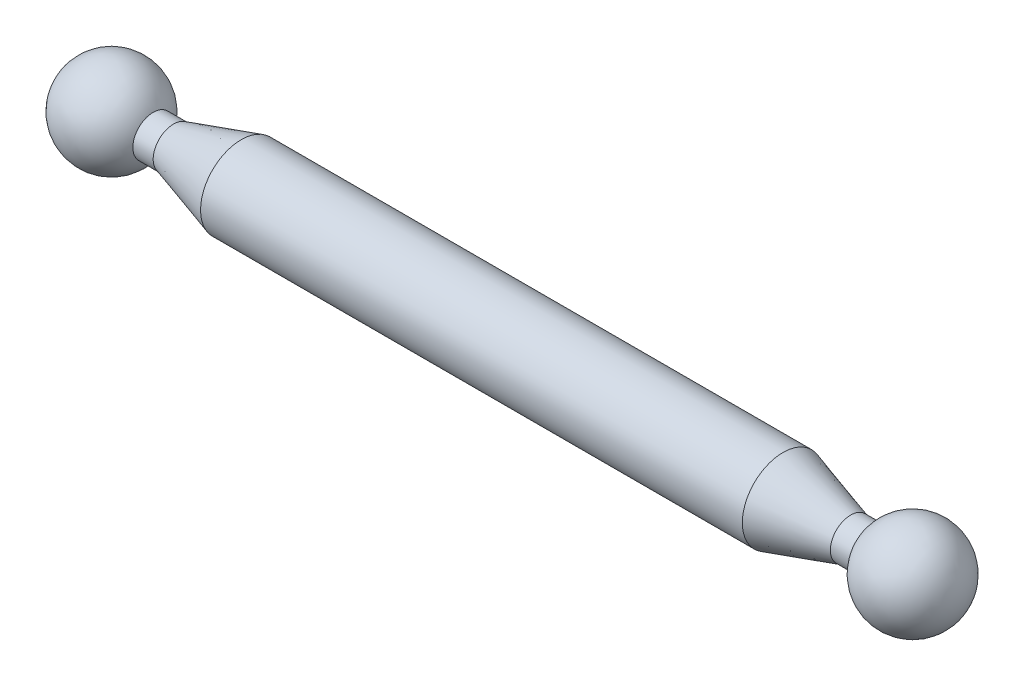
from build123d import *

# Parameters (mm, degrees)
DOME1_FACE_RADIUS = 15
DOME1_HEIGHT      = 65
DOME2_FACE_RADIUS = 15
DOME2_HEIGHT      = 65


with BuildPart() as part:
    # Sketch2 → Revolve1 (revolve)
    with BuildSketch(Plane.XY):
        Polygon((-265, 0), (265, 0), (265, 15), (250, 15), (200, 30), (-200, 30), (-250, 15), (-265, 15), align=None)
    revolve(axis=Axis((-265, 0, 0), (1, 0, 0)))

    # Dome1: a dome of height H over a round flat face of radius A is a cap of a sphere of radius (A * A + H * H) / (2 * H)
    dome1_r = (DOME1_FACE_RADIUS * DOME1_FACE_RADIUS + DOME1_HEIGHT * DOME1_HEIGHT) / (2 * DOME1_HEIGHT)
    dome1_base = Plane((265, 0, 0), z_dir=(1, 0, 0))
    with Locations(dome1_base.offset(DOME1_HEIGHT - dome1_r)):
        dome1_ball = Sphere(dome1_r, mode=Mode.PRIVATE)
    add(split(dome1_ball, bisect_by=dome1_base, keep=Keep.TOP, mode=Mode.PRIVATE))

    # Dome2: a dome of height H over a round flat face of radius A is a cap of a sphere of radius (A * A + H * H) / (2 * H)
    dome2_r = (DOME2_FACE_RADIUS * DOME2_FACE_RADIUS + DOME2_HEIGHT * DOME2_HEIGHT) / (2 * DOME2_HEIGHT)
    dome2_base = Plane((-265, 0, 0), z_dir=(-1, 0, 0))
    with Locations(dome2_base.offset(DOME2_HEIGHT - dome2_r)):
        dome2_ball = Sphere(dome2_r, mode=Mode.PRIVATE)
    add(split(dome2_ball, bisect_by=dome2_base, keep=Keep.TOP, mode=Mode.PRIVATE))


solid = part.part
